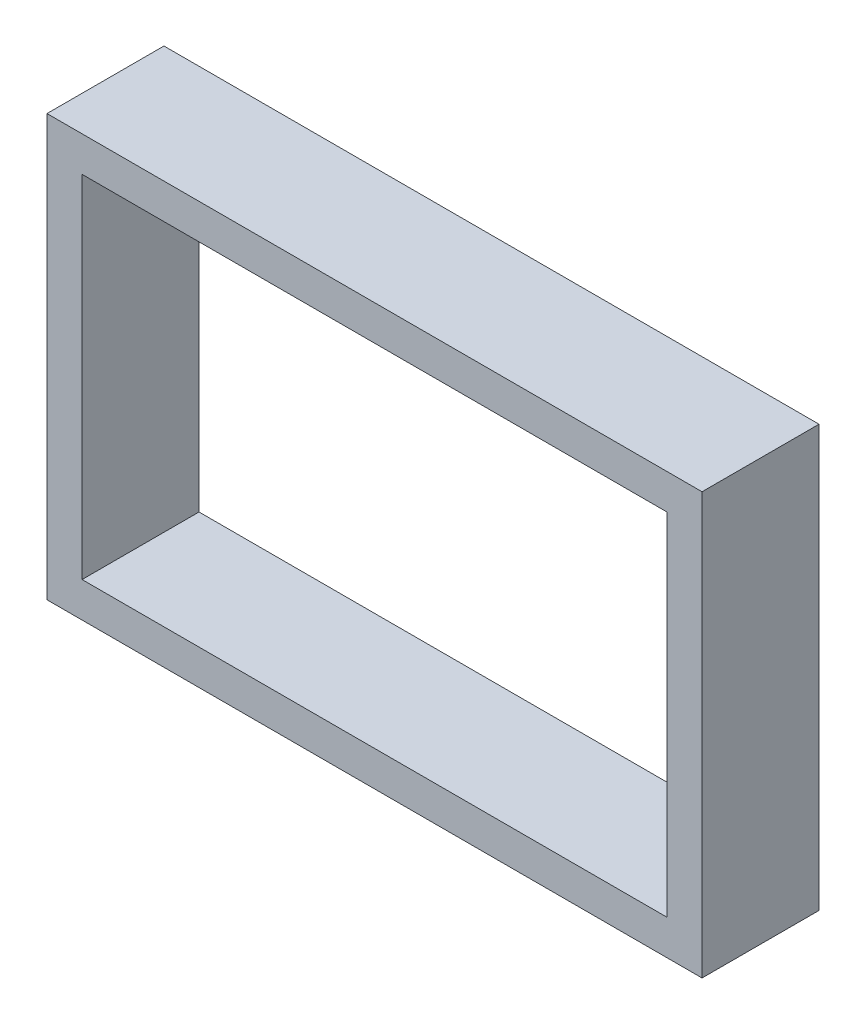
from build123d import *

# Parameters (mm, degrees)
SKETCH_1_W      = 56
SKETCH_1_H      = 36
SKETCH_1_W_2    = 50
SKETCH_1_H_2    = 30
EXTRUDE_1_DEPTH = 10


with BuildPart() as part:
    # 草圖1 → 填料-伸長1 (new body)
    with BuildSketch(Plane.XY):
        Rectangle(SKETCH_1_W, SKETCH_1_H)
        Rectangle(SKETCH_1_W_2, SKETCH_1_H_2, mode=Mode.SUBTRACT)
    extrude(amount=EXTRUDE_1_DEPTH)


solid = part.part
